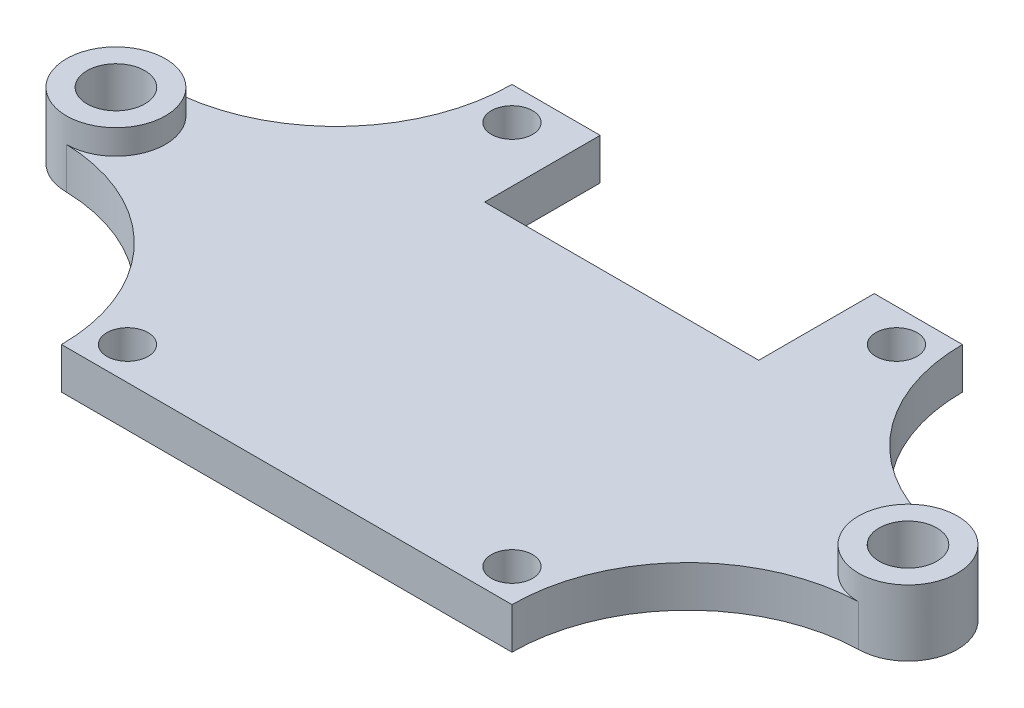
from build123d import *

# Parameters (mm, degrees)
SKETCH2_R           = 1.25
BOSS_EXTRUDE1_DEPTH = 2.5
SKETCH2_4_R         = 3
SKETCH2_4_R_2       = 1.75
BOSS_EXTRUDE2_DEPTH = 4
SKETCH3_W           = 16.608695652
SKETCH3_H           = 7
CUT_EXTRUDE1_DEPTH  = 3.25


with BuildPart() as part:
    # Sketch2 → Boss-Extrude1 (new body)
    with BuildSketch(Plane(origin=(0, 0, 0), x_dir=(1, 0, 0), z_dir=(0, 1, 0))):
        with BuildLine():
            Line((27.3, 27.3), (0, 27.3))
            ThreePointArc((0, 27.3), (-3.013740677, 19.874621222), (-10.35, 16.65))
            ThreePointArc((-10.35, 16.65), (-7.35, 13.65), (-10.35, 10.65))
            ThreePointArc((-10.35, 10.65), (-3.013740677, 7.425378778), (0, 0))
            Line((0, 0), (27.3, 0))
            ThreePointArc((27.3, 0), (30.313740677, 7.425378778), (37.65, 10.65))
            ThreePointArc((37.65, 10.65), (34.65, 13.65), (37.65, 16.65))
            ThreePointArc((37.65, 16.65), (30.313740677, 19.874621222), (27.3, 27.3))
        make_face()
        with Locations((2, 25.3)):
            Circle(SKETCH2_R, mode=Mode.SUBTRACT)
        with Locations((2, 2)):
            Circle(SKETCH2_R, mode=Mode.SUBTRACT)
        with Locations((25.3, 2)):
            Circle(SKETCH2_R, mode=Mode.SUBTRACT)
        with Locations((25.3, 25.3)):
            Circle(SKETCH2_R, mode=Mode.SUBTRACT)
    extrude(amount=BOSS_EXTRUDE1_DEPTH)

    # Sketch2_4 → Boss-Extrude2 (add)
    # profile 1 of 2: a face of its own
    with BuildSketch(Plane(origin=(0, 0, 0), x_dir=(1, 0, 0), z_dir=(0, 1, 0))):
        with Locations((-10.35, 13.65)):
            Circle(SKETCH2_4_R)
        with Locations((-10.35, 13.65)):
            Circle(SKETCH2_4_R_2, mode=Mode.SUBTRACT)
    # profile 2 of 2: a face of its own
    with BuildSketch(Plane(origin=(0, 0, 0), x_dir=(1, 0, 0), z_dir=(0, 1, 0))):
        with Locations((37.65, 13.65)):
            Circle(SKETCH2_4_R)
        with Locations((37.65, 13.65)):
            Circle(SKETCH2_4_R_2, mode=Mode.SUBTRACT)
    extrude(amount=BOSS_EXTRUDE2_DEPTH)

    # Sketch3 → Cut-Extrude1 (cut)
    with BuildSketch(Plane(origin=(0, 2.5, 0), x_dir=(1, 0, 0), z_dir=(0, 1, 0))):
        with Locations((13.65, 23.8)):
            Rectangle(SKETCH3_W, SKETCH3_H)
    extrude(amount=-CUT_EXTRUDE1_DEPTH, mode=Mode.SUBTRACT)


solid = part.part
